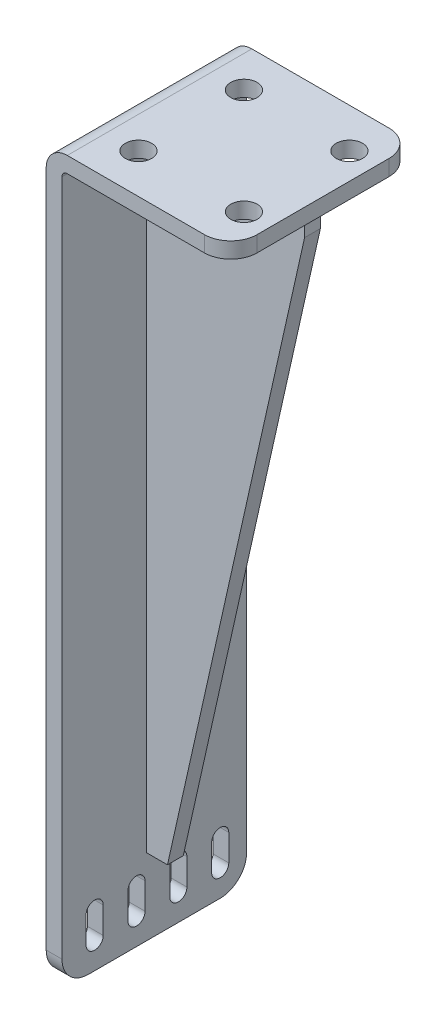
from build123d import *

# Parameters (mm, degrees)
EXTRUDE_1_DEPTH     = 70
FILLET_1_R          = 10
CUT_EXTRUDE_1_REACH = 72
CUT_EXTRUDE_2_REACH = 277
SKETCH_3_R          = 5
EXTRUDE_2_DEPTH     = 3


with BuildPart() as part:
    # 草图1 → 凸台-拉伸1 (new body)
    with BuildSketch(Plane.XY):
        with BuildLine():
            Line((8, 0), (70, 0))
            Line((70, 0), (70, -6))
            Line((70, -6), (8, -6))
            ThreePointArc((8, -6), (6.585786438, -6.585786438), (6, -8))
            Line((6, -8), (6, -275))
            Line((6, -275), (0, -275))
            Line((0, -275), (0, -8))
            ThreePointArc((0, -8), (2.343145751, -2.343145751), (8, 0))
        make_face()
    extrude(amount=EXTRUDE_1_DEPTH)

    # 圆角1
    fillet_1_edges = [part.edges().sort_by_distance(p)[0] for p in [
        (70, -3, 0),
        (3, -275, 70),
        (70, -3, 70),
        (3, -275, 0),
    ]]
    fillet(fillet_1_edges, radius=FILLET_1_R)

    # 草图2 → 切除-拉伸1 (cut, up to next)
    with BuildSketch(Plane.ZY, mode=Mode.PRIVATE) as cut_extrude_1_sk1:
        with BuildLine():
            Line((6.75, -255), (6.75, -265))
            ThreePointArc((6.75, -265), (10, -268.25), (13.25, -265))
            Line((13.25, -265), (13.25, -255))
            ThreePointArc((13.25, -255), (10, -251.75), (6.75, -255))
        make_face()
    cut_extrude_1_tool1 = extrude(cut_extrude_1_sk1.sketch, amount=-CUT_EXTRUDE_1_REACH, mode=Mode.PRIVATE) & part.part
    add(cut_extrude_1_tool1.solids().sort_by_distance((0, -260, 10))[0], mode=Mode.SUBTRACT)
    # 草图2 → 切除-拉伸1 (cut, up to next)
    with BuildSketch(Plane.ZY, mode=Mode.PRIVATE) as cut_extrude_1_sk2:
        with BuildLine():
            Line((22.625, -255), (22.625, -265))
            ThreePointArc((22.625, -265), (25.875, -268.25), (29.125, -265))
            Line((29.125, -265), (29.125, -255))
            ThreePointArc((29.125, -255), (25.875, -251.75), (22.625, -255))
        make_face()
    cut_extrude_1_tool2 = extrude(cut_extrude_1_sk2.sketch, amount=-CUT_EXTRUDE_1_REACH, mode=Mode.PRIVATE) & part.part
    add(cut_extrude_1_tool2.solids().sort_by_distance((0, -260, 25.875))[0], mode=Mode.SUBTRACT)
    # 草图2 → 切除-拉伸1 (cut, up to next)
    with BuildSketch(Plane.ZY, mode=Mode.PRIVATE) as cut_extrude_1_sk3:
        with BuildLine():
            Line((38.5, -255), (38.5, -265))
            ThreePointArc((38.5, -265), (41.75, -268.25), (45, -265))
            Line((45, -265), (45, -255))
            ThreePointArc((45, -255), (41.75, -251.75), (38.5, -255))
        make_face()
    cut_extrude_1_tool3 = extrude(cut_extrude_1_sk3.sketch, amount=-CUT_EXTRUDE_1_REACH, mode=Mode.PRIVATE) & part.part
    add(cut_extrude_1_tool3.solids().sort_by_distance((0, -260, 41.75))[0], mode=Mode.SUBTRACT)
    # 草图2 → 切除-拉伸1 (cut, up to next)
    with BuildSketch(Plane.ZY, mode=Mode.PRIVATE) as cut_extrude_1_sk4:
        with BuildLine():
            Line((54.375, -255), (54.375, -265))
            ThreePointArc((54.375, -265), (57.625, -268.25), (60.875, -265))
            Line((60.875, -265), (60.875, -255))
            ThreePointArc((60.875, -255), (57.625, -251.75), (54.375, -255))
        make_face()
    cut_extrude_1_tool4 = extrude(cut_extrude_1_sk4.sketch, amount=-CUT_EXTRUDE_1_REACH, mode=Mode.PRIVATE) & part.part
    add(cut_extrude_1_tool4.solids().sort_by_distance((0, -260, 57.625))[0], mode=Mode.SUBTRACT)

    # 草图3 → 切除-拉伸2 (cut, up to next)
    with BuildSketch(Plane(origin=(0, 0, 0), x_dir=(1, 0, 0), z_dir=(0, 1, 0)), mode=Mode.PRIVATE) as cut_extrude_2_sk1:
        with Locations((60, -15)):
            Circle(SKETCH_3_R)
    cut_extrude_2_tool1 = extrude(cut_extrude_2_sk1.sketch, amount=-CUT_EXTRUDE_2_REACH, mode=Mode.PRIVATE) & part.part
    add(cut_extrude_2_tool1.solids().sort_by_distance((60, 0, 15))[0], mode=Mode.SUBTRACT)
    # 草图3 → 切除-拉伸2 (cut, up to next)
    with BuildSketch(Plane(origin=(0, 0, 0), x_dir=(1, 0, 0), z_dir=(0, 1, 0)), mode=Mode.PRIVATE) as cut_extrude_2_sk2:
        with Locations((20, -15)):
            Circle(SKETCH_3_R)
    cut_extrude_2_tool2 = extrude(cut_extrude_2_sk2.sketch, amount=-CUT_EXTRUDE_2_REACH, mode=Mode.PRIVATE) & part.part
    add(cut_extrude_2_tool2.solids().sort_by_distance((20, 0, 15))[0], mode=Mode.SUBTRACT)
    # 草图3 → 切除-拉伸2 (cut, up to next)
    with BuildSketch(Plane(origin=(0, 0, 0), x_dir=(1, 0, 0), z_dir=(0, 1, 0)), mode=Mode.PRIVATE) as cut_extrude_2_sk3:
        with Locations((20, -55)):
            Circle(SKETCH_3_R)
    cut_extrude_2_tool3 = extrude(cut_extrude_2_sk3.sketch, amount=-CUT_EXTRUDE_2_REACH, mode=Mode.PRIVATE) & part.part
    add(cut_extrude_2_tool3.solids().sort_by_distance((20, 0, 55))[0], mode=Mode.SUBTRACT)
    # 草图3 → 切除-拉伸2 (cut, up to next)
    with BuildSketch(Plane(origin=(0, 0, 0), x_dir=(1, 0, 0), z_dir=(0, 1, 0)), mode=Mode.PRIVATE) as cut_extrude_2_sk4:
        with Locations((60, -55)):
            Circle(SKETCH_3_R)
    cut_extrude_2_tool4 = extrude(cut_extrude_2_sk4.sketch, amount=-CUT_EXTRUDE_2_REACH, mode=Mode.PRIVATE) & part.part
    add(cut_extrude_2_tool4.solids().sort_by_distance((60, 0, 55))[0], mode=Mode.SUBTRACT)

    # 草图4 → 凸台-拉伸2 (add, symmetric)
    with BuildSketch(Plane(origin=(0, 0, 35), x_dir=(-1, 0, 0), z_dir=(0, 0, -1))):
        Polygon((-6, -14), (-6, -246), (-14, -246), (-66, -14), (-66, -6), (-14, -6), align=None)
    extrude(amount=EXTRUDE_2_DEPTH, both=True)


solid = part.part
